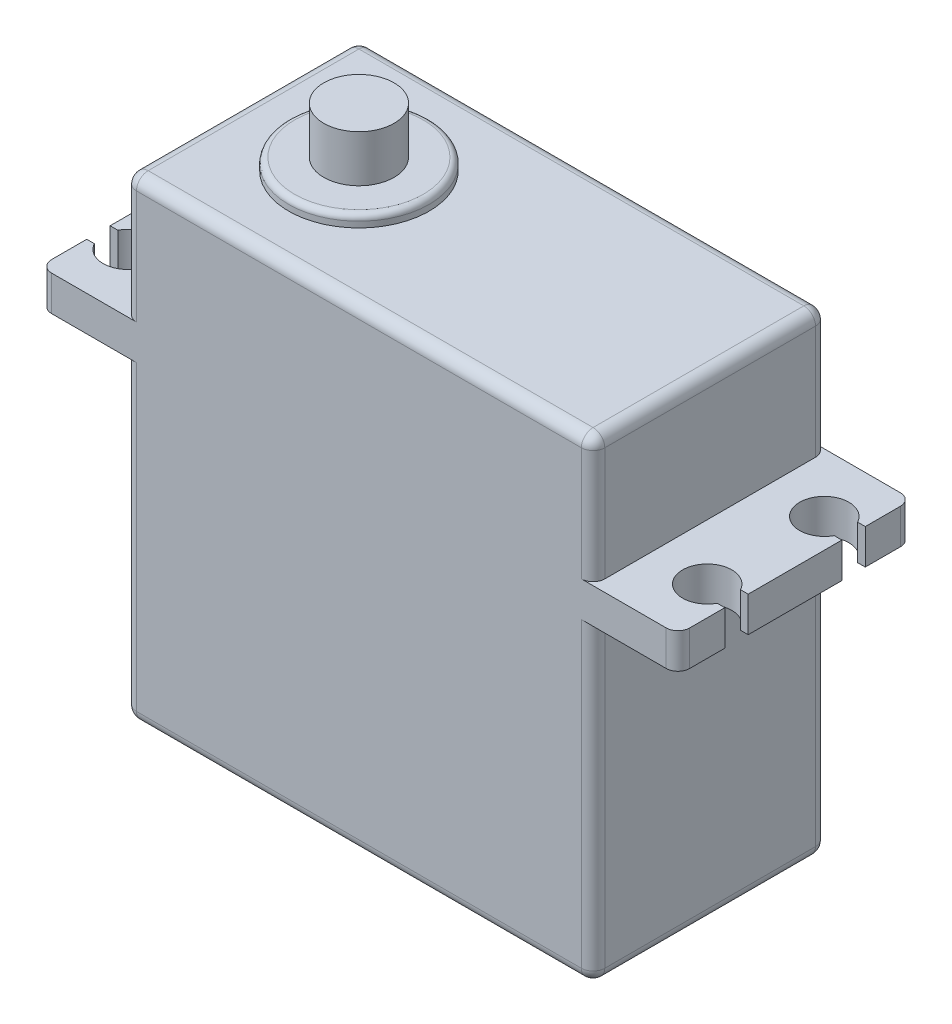
from build123d import *

# Parameters (mm, degrees)
SKETCH1_W           = 40
SKETCH1_H           = 20
BOSS_EXTRUDE1_DEPTH = 40.5
BOSS_EXTRUDE2_DEPTH = 3
FILLET1_R           = 1
SKETCH3_R           = 6
BOSS_EXTRUDE3_DEPTH = 1
SKETCH4_R           = 3
BOSS_EXTRUDE4_DEPTH = 4
FILLET2_R           = 0.5
FILLET3_R           = 1


with BuildPart() as part:
    # Sketch1 → Boss-Extrude1 (new body)
    with BuildSketch(Plane(origin=(0, 0, 0), x_dir=(1, 0, 0), z_dir=(0, 1, 0))):
        Rectangle(SKETCH1_W, SKETCH1_H)
    extrude(amount=BOSS_EXTRUDE1_DEPTH)

    # Sketch2 → Boss-Extrude2 (add)
    with BuildSketch(Plane(origin=(0, 26.8, 0), x_dir=(1, 0, 0), z_dir=(0, 1, 0))):
        with BuildLine():
            Line((-20, -10), (-20, 10))
            Line((-20, 10), (-27.25, 10))
            Line((-27.25, 10), (-27.25, 6))
            Line((-27.25, 6), (-26.596618531, 6))
            ThreePointArc((-26.596618531, 6), (-22.65, 5), (-26.596618531, 4))
            Line((-26.596618531, 4), (-27.25, 4))
            Line((-27.25, 4), (-27.25, -4))
            Line((-27.25, -4), (-26.596618531, -4))
            ThreePointArc((-26.596618531, -4), (-22.65, -5), (-26.596618531, -6))
            Line((-26.596618531, -6), (-27.25, -6))
            Line((-27.25, -6), (-27.25, -10))
            Line((-27.25, -10), (-20, -10))
        make_face()
        with BuildLine():
            Line((27.25, 10), (20, 10))
            Line((20, 10), (20, -10))
            Line((20, -10), (27.25, -10))
            Line((27.25, -10), (27.25, -6))
            Line((27.25, -6), (26.596618531, -6))
            ThreePointArc((26.596618531, -6), (22.65, -5), (26.596618531, -4))
            Line((26.596618531, -4), (27.25, -4))
            Line((27.25, -4), (27.25, 4))
            Line((27.25, 4), (26.596618531, 4))
            ThreePointArc((26.596618531, 4), (22.65, 5), (26.596618531, 6))
            Line((26.596618531, 6), (27.25, 6))
            Line((27.25, 6), (27.25, 10))
        make_face()
    extrude(amount=BOSS_EXTRUDE2_DEPTH)

    # Fillet1
    fillet1_edges = [part.edges().sort_by_distance(p)[0] for p in [
        (-27.25, 28.3, 10),
        (-27.25, 28.3, -10),
        (27.25, 28.3, -10),
        (27.25, 28.3, 10),
    ]]
    fillet(fillet1_edges, radius=FILLET1_R)

    # Sketch3 → Boss-Extrude3 (add)
    with BuildSketch(Plane(origin=(0, 40.5, 0), x_dir=(1, 0, 0), z_dir=(0, 1, 0))):
        with Locations((-10, 0)):
            Circle(SKETCH3_R)
    extrude(amount=BOSS_EXTRUDE3_DEPTH)

    # Sketch4 → Boss-Extrude4 (add)
    with BuildSketch(Plane(origin=(0, 41.5, 0), x_dir=(1, 0, 0), z_dir=(0, 1, 0))):
        with Locations((-10, 0)):
            Circle(SKETCH4_R)
    extrude(amount=BOSS_EXTRUDE4_DEPTH)

    # Fillet2
    fillet2_edges = [part.edges().sort_by_distance(p)[0] for p in [
        (-16, 41.5, 0),
    ]]
    fillet(fillet2_edges, radius=FILLET2_R)

    # Fillet3
    fillet3_edges = [part.edges().sort_by_distance(p)[0] for p in [
        (-20, 40.5, 0),
        (0, 40.5, 10),
        (-20, 13.4, 10),
        (-20, 13.4, -10),
        (20, 13.4, -10),
        (20, 13.4, 10),
        (20, 40.5, 0),
        (0, 0, 10),
        (-20, 0, 0),
        (0, 0, -10),
        (20, 0, 0),
        (0, 40.5, -10),
        (20, 35.15, 10),
        (-20, 35.15, 10),
        (-20, 35.15, -10),
        (20, 35.15, -10),
    ]]
    fillet(fillet3_edges, radius=FILLET3_R)


solid = part.part
